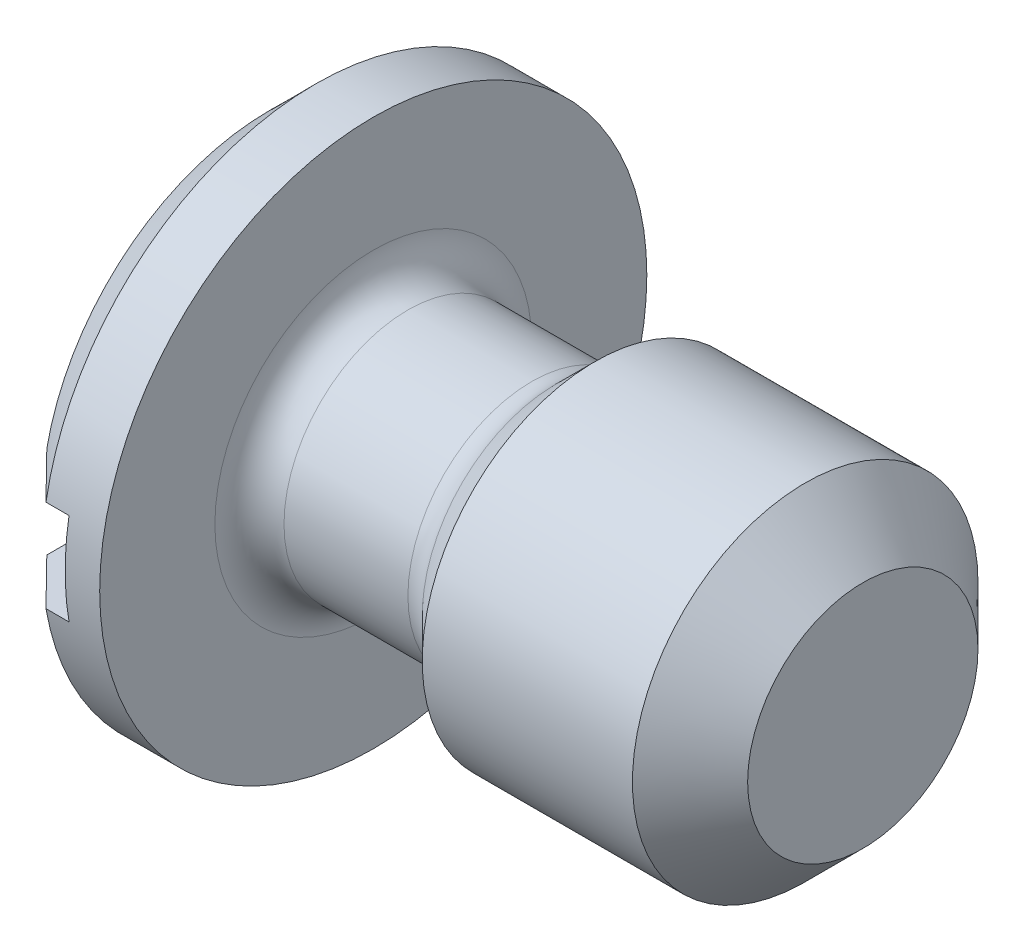
from build123d import *

# Parameters (mm, degrees)
CHAMFER_1_SIZE           = 1
FILLET_1_R               = 0.6
CHAMFER_2_SIZE           = 0.8
SKETCH_2_W               = 1.2
SKETCH_2_H               = 1.6
CUT_EXTRUDE_1_DEPTH      = 5.75
CUT_EXTRUDE_1_DEPTH_BACK = 5.75


with BuildPart() as part:
    # Эскиз1 → Повернуть1 (revolve)
    with BuildSketch(Plane.XY):
        Polygon((0, 0), (0, 4.75), (1.8, 4.75), (1.8, 2.15), (4.8, 2.15), (5.65, 3), (10.3, 3), (10.3, 0), align=None)
    revolve(axis=Axis((0, 0, 0), (-1, 0, 0)))

    # Фаска1
    chamfer_1_edges = [part.edges().sort_by_distance(p)[0] for p in [
        (10.3, -3, 0),
    ]]
    chamfer(chamfer_1_edges, length=CHAMFER_1_SIZE)

    # Скругление1
    fillet_1_edges = [part.edges().sort_by_distance(p)[0] for p in [
        (4.8, -2.15, 0),
        (1.8, -2.15, 0),
    ]]
    fillet(fillet_1_edges, radius=FILLET_1_R)

    # Фаска2
    chamfer_2_edges = [part.edges().sort_by_distance(p)[0] for p in [
        (0, -4.75, 0),
    ]]
    chamfer(chamfer_2_edges, length=CHAMFER_2_SIZE)

    # Эскиз2 → Вырез-Вытянуть1 (cut, two sides)
    with BuildSketch(Plane.XY) as cut_extrude_1_sk:
        with Locations((0.6, 0)):
            Rectangle(SKETCH_2_W, SKETCH_2_H)
    extrude(amount=CUT_EXTRUDE_1_DEPTH, mode=Mode.SUBTRACT)
    extrude(cut_extrude_1_sk.sketch, amount=-CUT_EXTRUDE_1_DEPTH_BACK, mode=Mode.SUBTRACT)


solid = part.part
